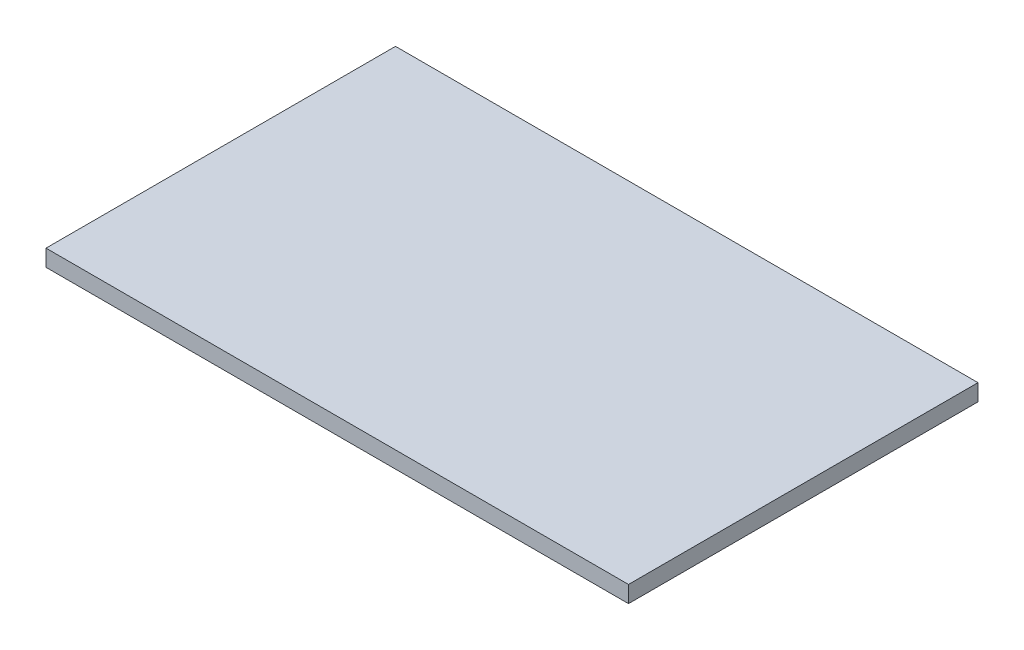
from build123d import *

# Parameters (mm, degrees)
ESQUISSE1_W      = 350
ESQUISSE1_H      = 210
EXTRUSION1_DEPTH = 10


with BuildPart() as part:
    # Esquisse1 → Extrusion1 (new body)
    with BuildSketch(Plane(origin=(0, 0, 0), x_dir=(1, 0, 0), z_dir=(0, 1, 0))):
        with Locations((175, 105)):
            Rectangle(ESQUISSE1_W, ESQUISSE1_H)
    extrude(amount=EXTRUSION1_DEPTH)


solid = part.part
